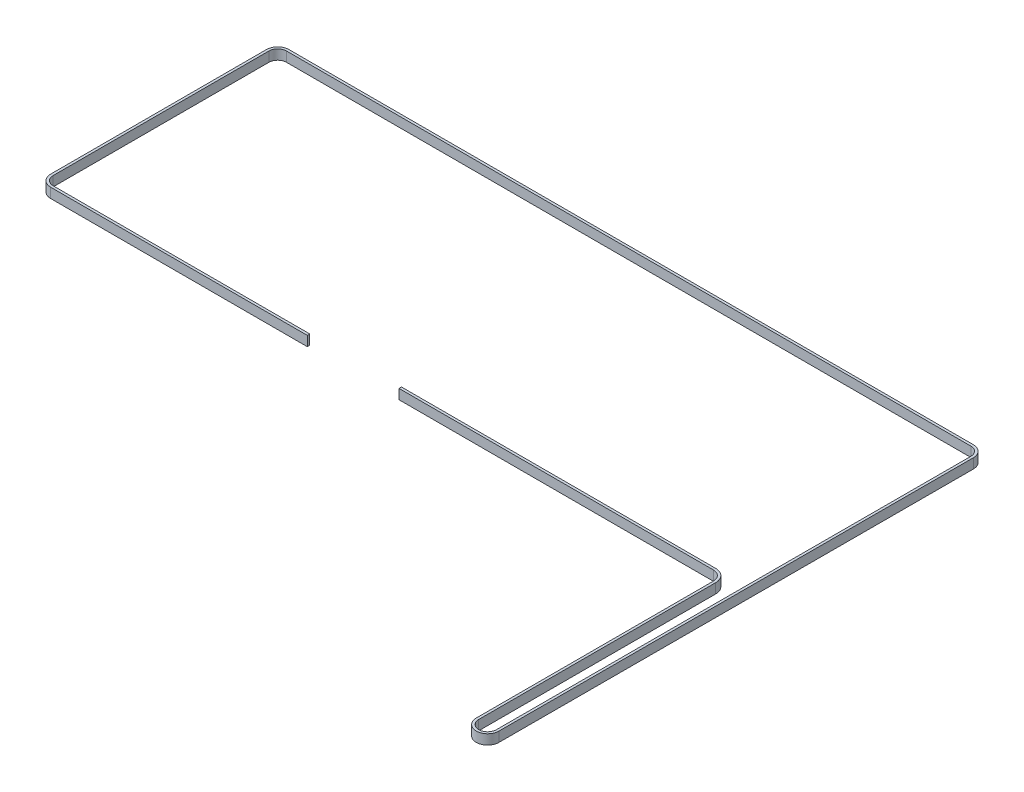
from build123d import *

# Parameters (mm, degrees)
BOSS_EXTRUDE1_DEPTH = 6


with BuildPart() as part:
    # Sketch1 → Boss-Extrude1 (new body)
    with BuildSketch(Plane(origin=(0, 321, 0), x_dir=(1, 0, 0), z_dir=(0, 1, 0))):
        with BuildLine():
            Line((195.6, 23.007337011), (3.974945104, 23.007337011))
            Line((3.974945104, 23.007337011), (3.974945104, 21.507337011))
            Line((3.974945104, 21.507337011), (195.6, 21.507337011))
            ThreePointArc((195.6, 21.507337011), (199.842640687, 19.749977698), (201.6, 15.507337011))
            Line((201.6, 15.507337011), (201.6, -129))
            ThreePointArc((201.6, -129), (208.496418687, -135.899999071), (215.399996282, -129.007162626))
            Line((215.399996282, -129.007162626), (215.699996282, 159.992837374))
            ThreePointArc((215.699996282, 159.992837374), (213.681568504, 164.876503762), (208.8, 166.9))
            Line((208.8, 166.9), (-208.5, 166.9))
            ThreePointArc((-208.5, 166.9), (-213.37903679, 164.87903679), (-215.4, 160))
            Line((-215.4, 160), (-215.4, 28.457337011))
            ThreePointArc((-215.4, 28.457337011), (-213.37903679, 23.578300221), (-208.5, 21.557337011))
            Line((-208.5, 21.557337011), (-52.025054896, 21.557337011))
            Line((-52.025054896, 21.557337011), (-52.025054896, 23.057337011))
            Line((-52.025054896, 23.057337011), (-208.5, 23.057337011))
            ThreePointArc((-208.5, 23.057337011), (-212.318376618, 24.638960392), (-213.9, 28.457337011))
            Line((-213.9, 28.457337011), (-213.9, 160))
            ThreePointArc((-213.9, 160), (-212.318376618, 163.818376618), (-208.5, 165.4))
            Line((-208.5, 165.4), (208.8, 165.4))
            ThreePointArc((208.8, 165.4), (212.62035796, 163.816394249), (214.199997091, 159.994394467))
            Line((214.199997091, 159.994394467), (213.899997091, -129.005605533))
            ThreePointArc((213.899997091, -129.005605533), (208.497197233, -134.399999273), (203.1, -129))
            Line((203.1, -129), (203.1, 15.507337011))
            ThreePointArc((203.1, 15.507337011), (200.903300859, 20.81063787), (195.6, 23.007337011))
        make_face()
    extrude(amount=-BOSS_EXTRUDE1_DEPTH)


solid = part.part
